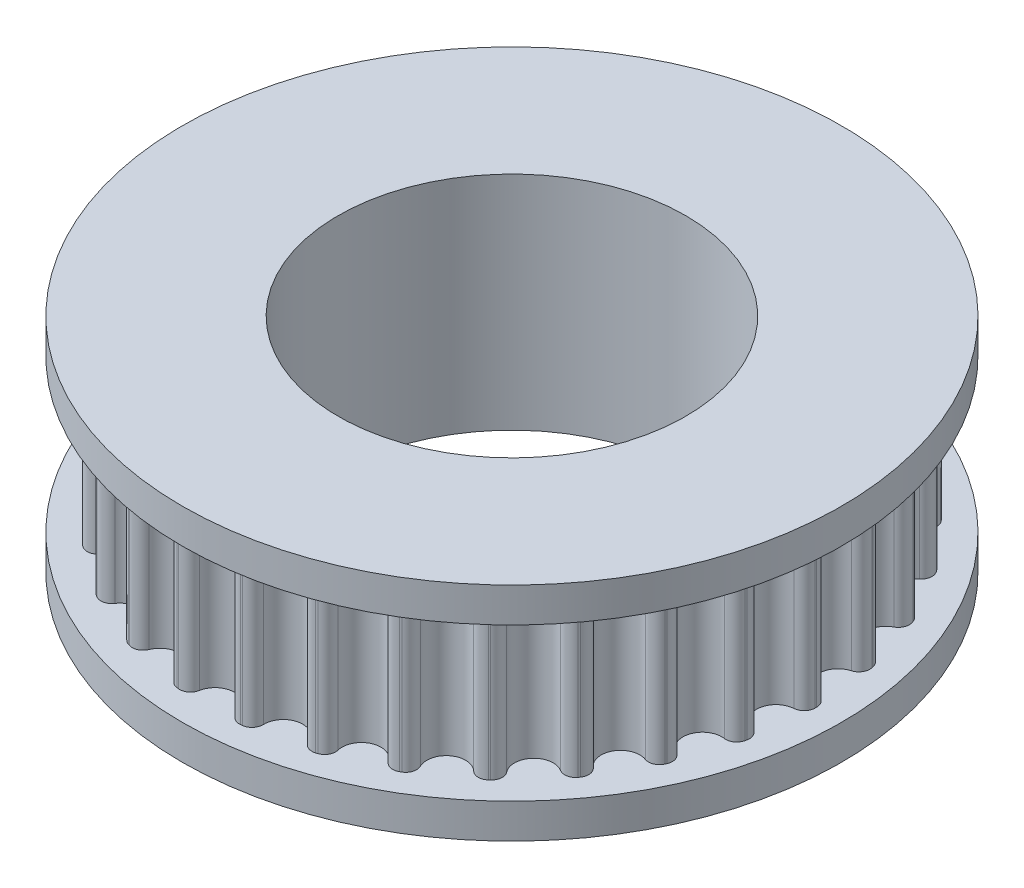
from build123d import *

# Parameters (mm, degrees)
BOSS_EXTRUDE1_DEPTH     = 3.499999985
CIRPATTERN1_COUNT       = 30
SKETCH2_W               = 15.117118674
SKETCH2_H               = 1.5875
SKETCH3_R               = 7.973368674
CUT_EXTRUDE1_DEPTH      = 6.087499985
CUT_EXTRUDE1_DEPTH_BACK = 6.087499985


with BuildPart() as part:
    # Sketch1 → Boss-Extrude1 (new body, symmetric)
    with BuildSketch(Plane(origin=(0, 0, 0), x_dir=(1, 0, 0), z_dir=(0, 1, 0))):
        with BuildLine():
            ThreePointArc((0, 12.722368574), (0.572445442, 12.930895013), (0.876643672, 13.458759102))
            ThreePointArc((0.876643672, 13.458759102), (1.067482498, 13.771213054), (1.420066433, 13.869861411))
            ThreePointArc((1.420066433, 13.869861411), (1.457374372, 13.86599092), (1.494671763, 13.862020075))
            ThreePointArc((1.494671763, 13.862020075), (1.819040747, 13.692221099), (1.940746457, 13.346917393))
            ThreePointArc((1.940746457, 13.346917393), (2.12854811, 12.767342032), (2.645129161, 12.444354296))
            ThreePointArc((2.645129161, 12.444354296), (-1.329849636, -12.652674108), (0, 12.722368574))
        make_face()
    boss_extrude1 = extrude(amount=BOSS_EXTRUDE1_DEPTH, both=True)

    # CirPattern1: Boss-Extrude1 ×30 about axis
    cirpattern1_axis = Axis((0, 0, 0), (0, 1, 0))
    for i in range(1, CIRPATTERN1_COUNT):
        add(boss_extrude1.rotate(cirpattern1_axis, i * 360 / CIRPATTERN1_COUNT))

    # Sketch2 → Revolve3 (revolve)
    with BuildSketch(Plane(origin=(0, 0, 0), x_dir=(0, 0, -1), z_dir=(1, 0, 0))):
        with Locations((7.558559337, 4.293749985)):
            Rectangle(SKETCH2_W, SKETCH2_H)
    revolve3 = revolve(axis=Axis((0, 3.3, 0), (0, -1, 0)))

    # Mirror1: Revolve3 across plane
    add(revolve3.mirror(Plane.ZX))

    # Sketch3 → Cut-Extrude1 (cut, two sides)
    with BuildSketch(Plane(origin=(0, 0, 0), x_dir=(-1, 0, 0), z_dir=(0, -1, 0))) as cut_extrude1_sk:
        Circle(SKETCH3_R)
    extrude(amount=CUT_EXTRUDE1_DEPTH, mode=Mode.SUBTRACT)
    extrude(cut_extrude1_sk.sketch, amount=-CUT_EXTRUDE1_DEPTH_BACK, mode=Mode.SUBTRACT)


solid = part.part
